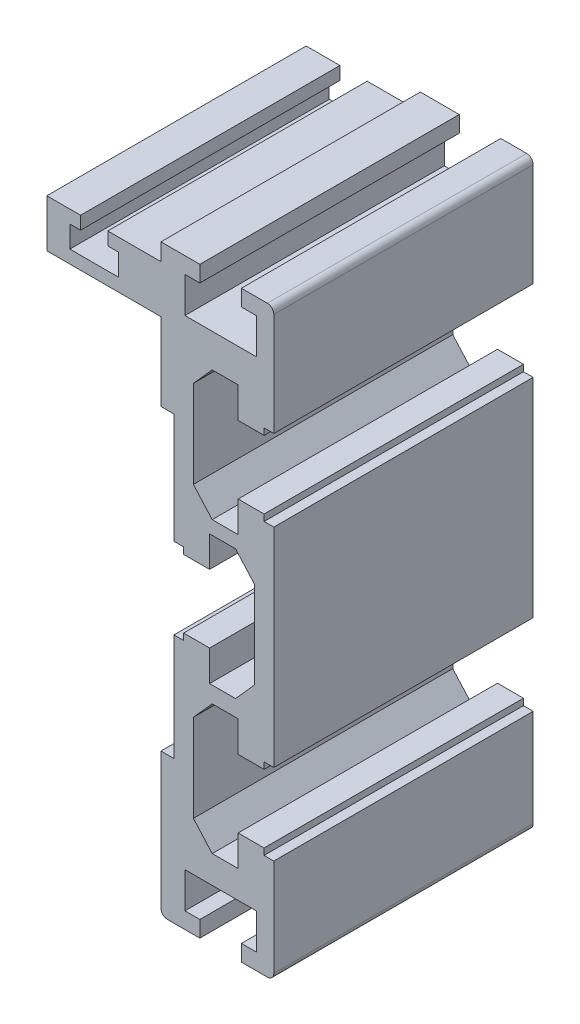
from build123d import *

# Parameters (mm, degrees)
EXTRUDE_1_DEPTH = 40


with BuildPart() as part:
    # Model → Бобышка-Вытянуть1 (new body)
    with BuildSketch(Plane.XY):
        with BuildLine():
            Line((-2.7, -8), (2.3, -8))
            Line((2.3, -8), (2.3, -5.5))
            Line((2.3, -5.5), (0, -5.5))
            Line((0, -5.5), (0, 0))
            Line((0, 0), (11, 0))
            Line((11, 0), (11, -5.5))
            Line((11, -5.5), (8.7, -5.5))
            Line((8.7, -5.5), (8.7, -8))
            Line((8.7, -8), (12.7, -8))
            ThreePointArc((12.7, -8), (13.407106781, -7.707106781), (13.7, -7))
            Line((13.7, -7), (13.7, 8))
            Line((13.7, 8), (12.2, 8))
            Line((12.2, 8), (12.2, 9))
            Line((12.2, 9), (8.2, 9))
            Line((8.2, 9), (8.2, 4.25))
            Line((8.2, 4.25), (4.2, 4.25))
            Line((4.2, 4.25), (1.3, 7.5))
            Line((1.3, 7.5), (1.3, 21))
            Line((1.3, 21), (4.2, 24.25))
            Line((4.2, 24.25), (8.2, 24.25))
            Line((8.2, 24.25), (8.2, 19.5))
            Line((8.2, 19.5), (12.2, 19.5))
            Line((12.2, 19.5), (12.2, 20.5))
            Line((12.2, 20.5), (13.7, 20.5))
            Line((13.7, 20.5), (13.7, 52.6))
            Line((13.7, 52.6), (12.2, 52.6))
            Line((12.2, 52.6), (12.2, 53.6))
            Line((12.2, 53.6), (8.2, 53.6))
            Line((8.2, 53.6), (8.2, 48.85))
            Line((8.2, 48.85), (4.2, 48.85))
            Line((4.2, 48.85), (1.3, 52.1))
            Line((1.3, 52.1), (1.3, 65.6))
            Line((1.3, 65.6), (4.2, 68.85))
            Line((4.2, 68.85), (8.2, 68.85))
            Line((8.2, 68.85), (8.2, 64.1))
            Line((8.2, 64.1), (12.2, 64.1))
            Line((12.2, 64.1), (12.2, 65.1))
            Line((12.2, 65.1), (13.7, 65.1))
            Line((13.7, 65.1), (13.7, 81))
            ThreePointArc((13.7, 81), (13.407106781, 81.707106781), (12.7, 82))
            Line((12.7, 82), (8.7, 82))
            Line((8.7, 82), (8.7, 79.5))
            Line((8.7, 79.5), (11, 79.5))
            Line((11, 79.5), (11, 74))
            Line((11, 74), (0, 74))
            Line((0, 74), (0, 79.5))
            Line((0, 79.5), (2.3, 79.5))
            Line((2.3, 79.5), (2.3, 82))
            Line((2.3, 82), (-3.7, 82))
            Line((-3.7, 82), (-3.7, 79.35))
            Line((-3.7, 79.35), (-11.9, 79.35))
            Line((-11.9, 79.35), (-11.9, 77.35))
            Line((-11.9, 77.35), (-10.25, 77.35))
            Line((-10.25, 77.35), (-10.25, 74))
            Line((-10.25, 74), (-17.75, 74))
            Line((-17.75, 74), (-17.75, 77.35))
            Line((-17.75, 77.35), (-16.1, 77.35))
            Line((-16.1, 77.35), (-16.1, 79.35))
            Line((-16.1, 79.35), (-21.3, 79.35))
            Line((-21.3, 79.35), (-21.3, 72))
            Line((-21.3, 72), (-3.7, 72))
            Line((-3.7, 72), (-3.7, 60))
            Line((-3.7, 60), (-1.7, 60))
            Line((-1.7, 60), (-1.7, 43))
            Line((-1.7, 43), (-0.2, 43))
            Line((-0.2, 43), (-0.2, 42))
            Line((-0.2, 42), (3.8, 42))
            Line((3.8, 42), (3.8, 46.75))
            Line((3.8, 46.75), (7.8, 46.75))
            Line((7.8, 46.75), (10.7, 43.5))
            Line((10.7, 43.5), (10.7, 30))
            Line((10.7, 30), (7.8, 26.75))
            Line((7.8, 26.75), (3.8, 26.75))
            Line((3.8, 26.75), (3.8, 31.5))
            Line((3.8, 31.5), (-0.2, 31.5))
            Line((-0.2, 31.5), (-0.2, 30.5))
            Line((-0.2, 30.5), (-1.7, 30.5))
            Line((-1.7, 30.5), (-1.7, 14))
            Line((-1.7, 14), (-3.7, 14))
            Line((-3.7, 14), (-3.7, -7))
            ThreePointArc((-3.7, -7), (-3.407106781, -7.707106781), (-2.7, -8))
        make_face()
    extrude(amount=EXTRUDE_1_DEPTH)


solid = part.part
